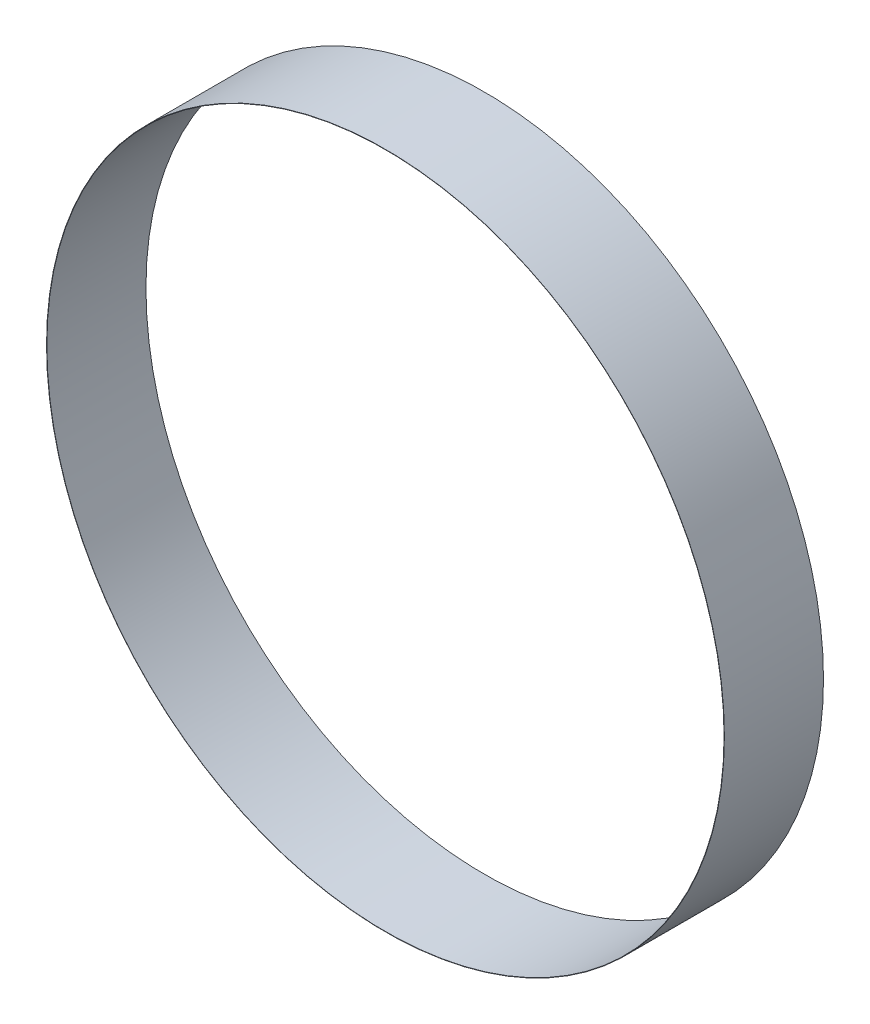
from build123d import *

# Parameters (mm, degrees)
SKETCH_1_R      = 102.6
SKETCH_1_R_2    = 102.5
EXTRUDE_1_DEPTH = 30


with BuildPart() as part:
    # 草图1 → 凸台-拉伸1 (new body)
    with BuildSketch(Plane.XY):
        Circle(SKETCH_1_R)
        Circle(SKETCH_1_R_2, mode=Mode.SUBTRACT)
    extrude(amount=EXTRUDE_1_DEPTH)


solid = part.part
